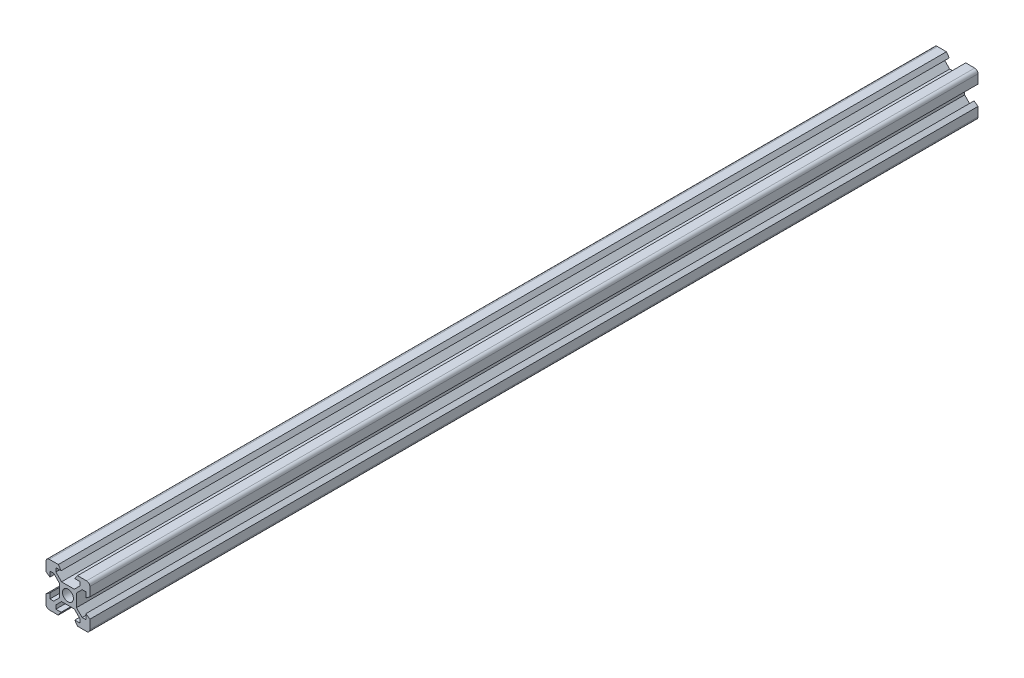
from build123d import *

# Parameters (mm, degrees)
SKETCH_1_R      = 2.5
EXTRUDE_1_DEPTH = 405


with BuildPart() as part:
    # 草图1 → 凸台-拉伸1 (new body)
    with BuildSketch(Plane.XY):
        with BuildLine():
            Line((14.8, 34.821428571), (18.9, 34.821428571))
            Line((18.9, 34.821428571), (20.2, 33.021428571))
            Line((20.2, 33.021428571), (17.8, 33.021428571))
            Line((17.8, 33.021428571), (17.8, 31.311378065))
            Line((17.8, 31.311378065), (20.389949494, 28.721428571))
            Line((20.389949494, 28.721428571), (26.210050506, 28.721428571))
            Line((26.210050506, 28.721428571), (28.8, 31.311378065))
            Line((28.8, 31.311378065), (28.8, 33.021428571))
            Line((28.8, 33.021428571), (26.4, 33.021428571))
            Line((26.4, 33.021428571), (27.7, 34.821428571))
            Line((27.7, 34.821428571), (31.8, 34.821428571))
            ThreePointArc((31.8, 34.821428571), (32.860660172, 34.382088743), (33.3, 33.321428571))
            Line((33.3, 33.321428571), (33.3, 29.221428571))
            Line((33.3, 29.221428571), (31.5, 27.921428571))
            Line((31.5, 27.921428571), (31.5, 30.321428571))
            Line((31.5, 30.321428571), (29.789949494, 30.321428571))
            Line((29.789949494, 30.321428571), (27.2, 27.731479078))
            Line((27.2, 27.731479078), (27.2, 21.911378065))
            Line((27.2, 21.911378065), (29.789949494, 19.321428571))
            Line((29.789949494, 19.321428571), (31.5, 19.321428571))
            Line((31.5, 19.321428571), (31.5, 21.721428571))
            Line((31.5, 21.721428571), (33.3, 20.421428571))
            Line((33.3, 20.421428571), (33.3, 16.321428571))
            ThreePointArc((33.3, 16.321428571), (32.860660172, 15.2607684), (31.8, 14.821428571))
            Line((31.8, 14.821428571), (27.7, 14.821428571))
            Line((27.7, 14.821428571), (26.4, 16.621428571))
            Line((26.4, 16.621428571), (28.8, 16.621428571))
            Line((28.8, 16.621428571), (28.8, 18.331479078))
            Line((28.8, 18.331479078), (26.210050506, 20.921428571))
            Line((26.210050506, 20.921428571), (20.389949494, 20.921428571))
            Line((20.389949494, 20.921428571), (17.8, 18.331479078))
            Line((17.8, 18.331479078), (17.8, 16.621428571))
            Line((17.8, 16.621428571), (20.2, 16.621428571))
            Line((20.2, 16.621428571), (18.9, 14.821428571))
            Line((18.9, 14.821428571), (14.8, 14.821428571))
            ThreePointArc((14.8, 14.821428571), (13.739339828, 15.2607684), (13.3, 16.321428571))
            Line((13.3, 16.321428571), (13.3, 20.421428571))
            Line((13.3, 20.421428571), (15.1, 21.721428571))
            Line((15.1, 21.721428571), (15.1, 19.321428571))
            Line((15.1, 19.321428571), (16.810050506, 19.321428571))
            Line((16.810050506, 19.321428571), (19.4, 21.911378065))
            Line((19.4, 21.911378065), (19.4, 27.731479078))
            Line((19.4, 27.731479078), (16.810050506, 30.321428571))
            Line((16.810050506, 30.321428571), (15.1, 30.321428571))
            Line((15.1, 30.321428571), (15.1, 27.921428571))
            Line((15.1, 27.921428571), (13.3, 29.221428571))
            Line((13.3, 29.221428571), (13.3, 33.321428571))
            ThreePointArc((13.3, 33.321428571), (13.739339828, 34.382088743), (14.8, 34.821428571))
        make_face()
        with Locations((23.3, 24.821428571)):
            Circle(SKETCH_1_R, mode=Mode.SUBTRACT)
    extrude(amount=EXTRUDE_1_DEPTH)


solid = part.part
